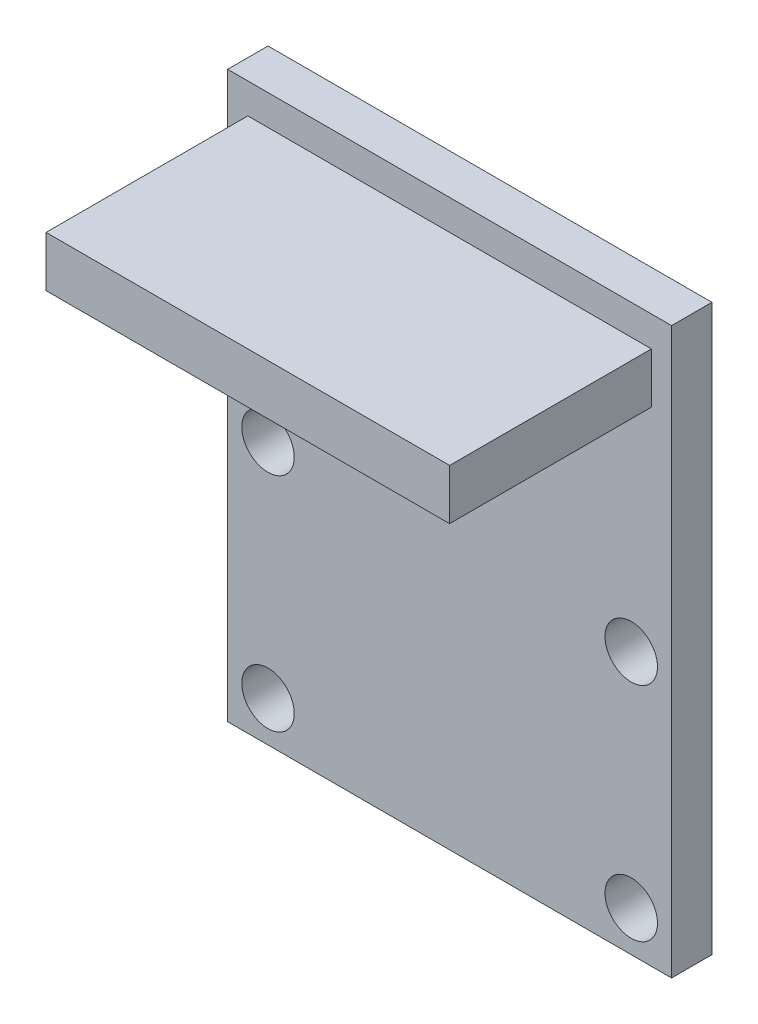
from build123d import *

# Parameters (mm, degrees)
SKETCH_1_W      = 22
SKETCH_1_H      = 28
SKETCH_1_R      = 1.3
EXTRUDE_1_DEPTH = 2
SKETCH_2_W      = 20
SKETCH_2_H      = 2.5
EXTRUDE_2_DEPTH = 10


with BuildPart() as part:
    # 草图1 → 凸台-拉伸1 (new body)
    with BuildSketch(Plane.XY):
        Rectangle(SKETCH_1_W, SKETCH_1_H)
        with Locations((-9, -11.997945994)):
            Circle(SKETCH_1_R, mode=Mode.SUBTRACT)
        with Locations((-9, -0.997945994)):
            Circle(SKETCH_1_R, mode=Mode.SUBTRACT)
        with Locations((9, -0.997945994)):
            Circle(SKETCH_1_R, mode=Mode.SUBTRACT)
        with Locations((9, -11.997945994)):
            Circle(SKETCH_1_R, mode=Mode.SUBTRACT)
    extrude(amount=EXTRUDE_1_DEPTH)

    # 草图2 → 凸台-拉伸2 (add)
    with BuildSketch(Plane.XY.offset(2)):
        with Locations((0, 11.25)):
            Rectangle(SKETCH_2_W, SKETCH_2_H)
    extrude(amount=EXTRUDE_2_DEPTH)


solid = part.part
